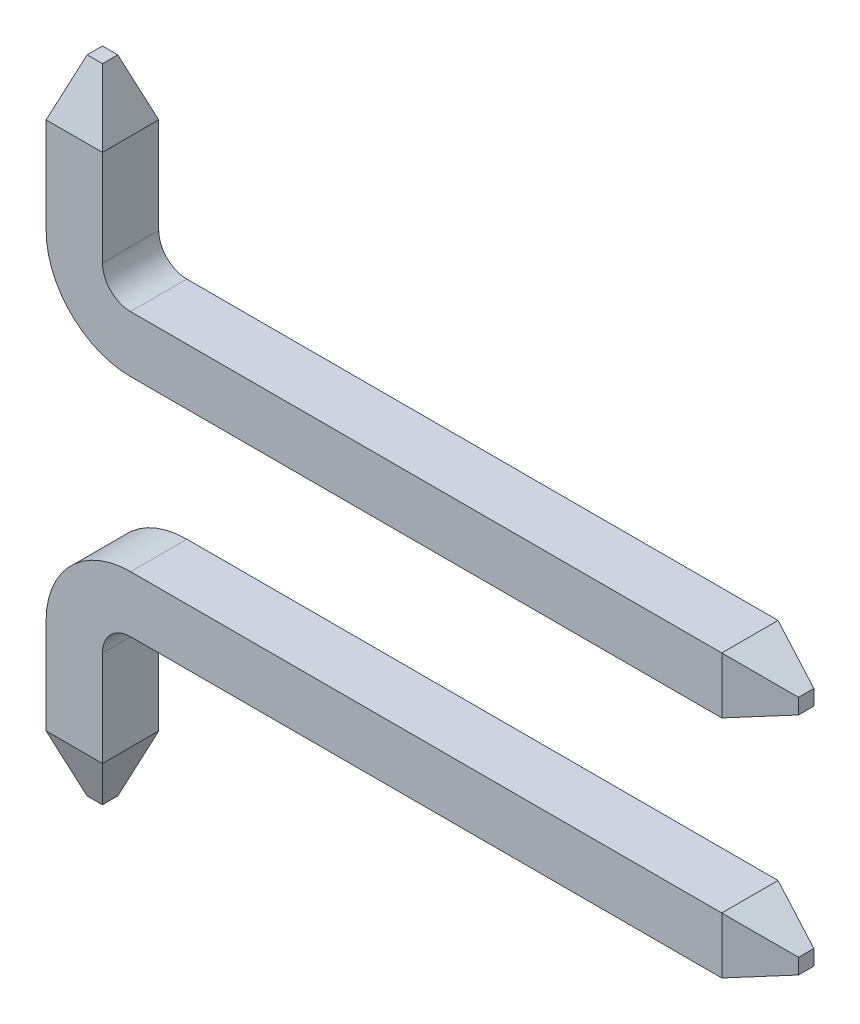
from build123d import *

# Parameters (mm, degrees)
SKETCH1_W           = 0.5
SKETCH1_H           = 0.5
SKETCH6_W           = 0.5
SKETCH6_H           = 0.5
BOSS_EXTRUDE1_DEPTH = 0.5
BOSS_EXTRUDE1_TAPER = 20
SKETCH7_W           = 0.5
SKETCH7_H           = 0.5
BOSS_EXTRUDE2_DEPTH = 0.5
BOSS_EXTRUDE2_TAPER = 20


with BuildPart() as part:
    # Sweep4: sweep along a path in Sketch2
    with BuildLine(Plane.XY) as sweep4_path:
        Line((0.25, 0), (0.25, 0.85))
        ThreePointArc((0.25, 0.85), (0.396446609, 1.203553391), (0.75, 1.35))
        Line((0.75, 1.35), (6, 1.35))
    # Sketch1 → Sweep4 (sweep)
    with BuildSketch(Plane(origin=(0, 0, 0), x_dir=(1, 0, 0), z_dir=(0, 1, 0))):
        with Locations((0.25, 0.25)):
            Rectangle(SKETCH1_W, SKETCH1_H)
    sweep(path=sweep4_path.line)

    # Sketch6 → Boss-Extrude1 (add)
    with BuildSketch(Plane(origin=(6, 0, 0), x_dir=(0, 0, -1), z_dir=(1, 0, 0))):
        with Locations((0.25, 1.35)):
            Rectangle(SKETCH6_W, SKETCH6_H)
    extrude(amount=BOSS_EXTRUDE1_DEPTH, taper=BOSS_EXTRUDE1_TAPER)

    # Sketch7 → Boss-Extrude2 (add)
    with BuildSketch(Plane.XZ):
        with Locations((0.25, -0.25)):
            Rectangle(SKETCH7_W, SKETCH7_H)
    extrude(amount=BOSS_EXTRUDE2_DEPTH, taper=BOSS_EXTRUDE2_TAPER)


with BuildPart() as body_2:
    # Mirror3: mirrored copy
    add(part.part.mirror(Plane.ZX.offset(2.35)))


solid = Compound([part.part, body_2.part])
